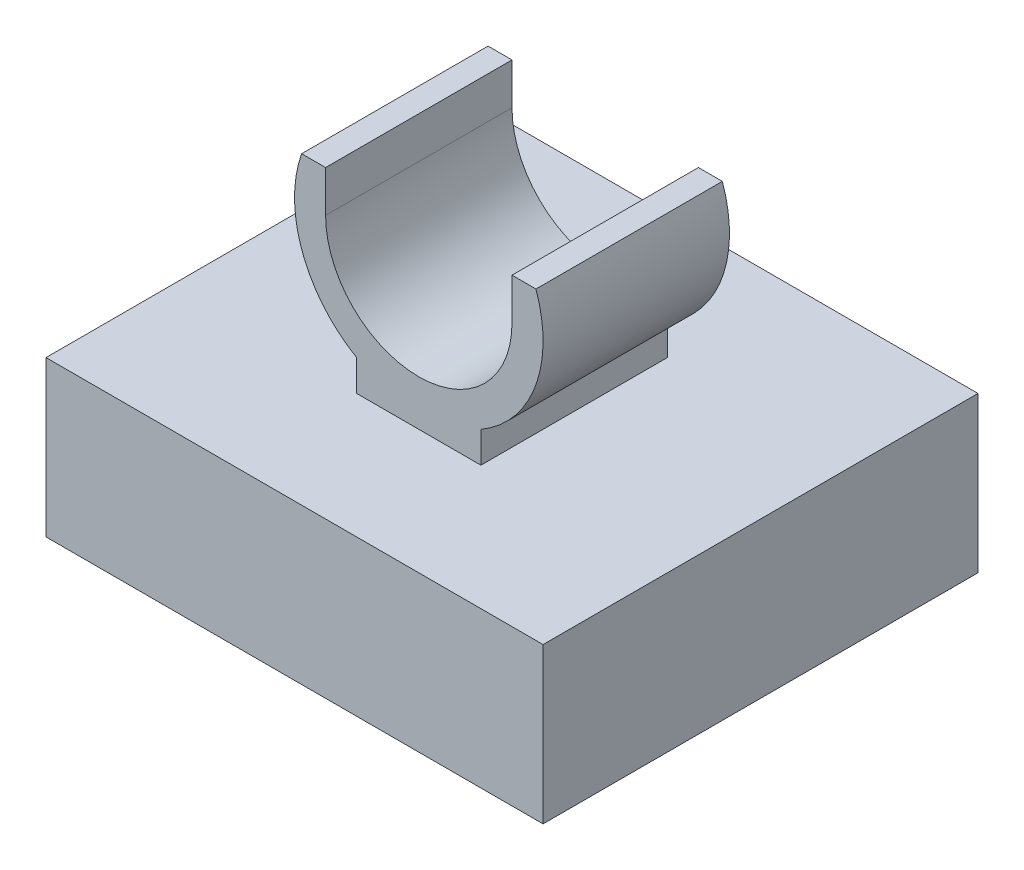
from build123d import *

# Parameters (mm, degrees)
SKETCH1_W           = 10.16
SKETCH1_H           = 3.175
BOSS_EXTRUDE1_DEPTH = 4.445
BOSS_EXTRUDE2_DEPTH = 1.905
SKETCH3_OUTSIDE_W   = 15.188
SKETCH3_OUTSIDE_H   = 13.918
SKETCH3_OUTSIDE_W_2 = 10.16
SKETCH3_OUTSIDE_H_2 = 8.89
SKETCH3_OUTSIDE_W_3 = 5.08
SKETCH3_OUTSIDE_H_3 = 5.08
CUT_EXTRUDE1_DEPTH  = 1.905


with BuildPart() as part:
    # Sketch1 → Boss-Extrude1 (new body, symmetric)
    with BuildSketch(Plane.XY):
        with Locations((0, -1.5875)):
            Rectangle(SKETCH1_W, SKETCH1_H)
    extrude(amount=BOSS_EXTRUDE1_DEPTH, both=True)

    # Sketch2 → Boss-Extrude2 (add, symmetric)
    with BuildSketch(Plane.XY):
        with BuildLine():
            Line((-1.905, 2.834704526), (-1.905, 3.681371192))
            Line((-1.905, 3.681371192), (-2.394734966, 3.681371192))
            ThreePointArc((-2.394734966, 3.681371192), (-2.382785125, 1.954968743), (-1.27, 0.635))
            Line((-1.27, 0.635), (-1.27, 0))
            Line((-1.27, 0), (1.27, 0))
            Line((1.27, 0), (1.27, 0.635))
            ThreePointArc((1.27, 0.635), (2.382785125, 1.954968743), (2.394734966, 3.681371192))
            Line((2.394734966, 3.681371192), (1.905, 3.681371192))
            Line((1.905, 3.681371192), (1.905, 2.834704526))
            ThreePointArc((1.905, 2.834704526), (0, 0.929704526), (-1.905, 2.834704526))
        make_face()
    extrude(amount=BOSS_EXTRUDE2_DEPTH, both=True)

    # Sketch3 outside → Cut-Extrude1 (cut)
    with BuildSketch(Plane.XZ.offset(3.175)):
        Rectangle(SKETCH3_OUTSIDE_W, SKETCH3_OUTSIDE_H)
        Rectangle(SKETCH3_OUTSIDE_W_2, SKETCH3_OUTSIDE_H_2, mode=Mode.SUBTRACT)
        Rectangle(SKETCH3_OUTSIDE_W_3, SKETCH3_OUTSIDE_H_3)
    extrude(amount=-CUT_EXTRUDE1_DEPTH, mode=Mode.SUBTRACT)


solid = part.part
